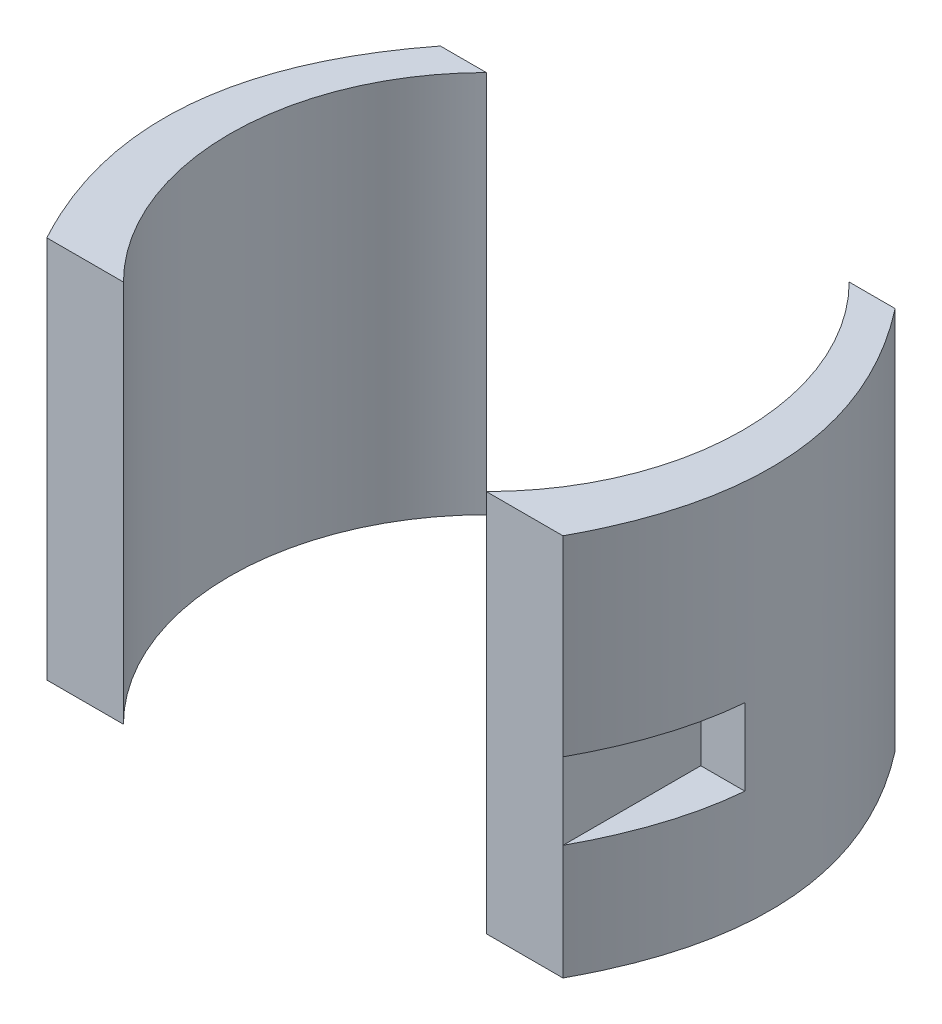
from build123d import *

# Parameters (mm, degrees)
BOSS_EXTRUDE1_DEPTH   = 50
BOSS_EXTRUDE1_2_DEPTH = 50
SKETCH3_W             = 8
SKETCH3_H             = 10
CUT_EXTRUDE5_DEPTH    = 18


with BuildPart() as part:
    # Sketch2 → Boss-Extrude1 (new body)
    with BuildSketch(Plane(origin=(0, 0, 0), x_dir=(1, 0, 0), z_dir=(0, 1, 0))):
        with BuildLine():
            ThreePointArc((-23.68807717, -23.68807717), (-33.5, 0), (-23.68807717, 23.68807717))
            Line((-23.68807717, 23.68807717), (-29.68807717, 23.68807717))
            add(Edge.make_bspline(
                [(-29.68807717, 23.68807717), (-47.221735333, 1.183613852), (-33.68807717, -23.68807717)],
                knots=[0, 0, 0, 1, 1, 1], degree=2))
            Line((-33.68807717, -23.68807717), (-23.68807717, -23.68807717))
        make_face()
    extrude(amount=BOSS_EXTRUDE1_DEPTH)


with BuildPart() as body_2:
    # Sketch2 → Boss-Extrude1 2 (new body)
    with BuildSketch(Plane(origin=(0, 0, 0), x_dir=(1, 0, 0), z_dir=(0, 1, 0))):
        with BuildLine():
            Line((29.68807717, 23.68807717), (23.68807717, 23.68807717))
            ThreePointArc((23.68807717, 23.68807717), (33.5, 0), (23.68807717, -23.68807717))
            Line((23.68807717, -23.68807717), (33.68807717, -23.68807717))
            add(Edge.make_bspline(
                [(29.68807717, 23.68807717), (47.221735333, 1.183613852), (33.68807717, -23.68807717)],
                knots=[0, 0, 0, 1, 1, 1], degree=2))
        make_face()
    extrude(amount=BOSS_EXTRUDE1_2_DEPTH)


with BuildPart() as cut_extrude5_tool:
    # Sketch3 → Cut-Extrude5 (new body)
    with BuildSketch(Plane.XY.offset(23.68807717)):
        with Locations((-37.68807717, 20)):
            Rectangle(SKETCH3_W, SKETCH3_H)
        with Locations((37.68807717, 20)):
            Rectangle(SKETCH3_W, SKETCH3_H)
    extrude(amount=-CUT_EXTRUDE5_DEPTH)


with BuildPart() as part_1:
    add(part.part)

    # Cut-Extrude5: cut by cut_extrude5_tool
    add(cut_extrude5_tool.part, mode=Mode.SUBTRACT)


with BuildPart() as body_2_1:
    add(body_2.part)

    # Cut-Extrude5: cut by cut_extrude5_tool
    add(cut_extrude5_tool.part, mode=Mode.SUBTRACT)


solid = Compound([part_1.part, body_2_1.part])
